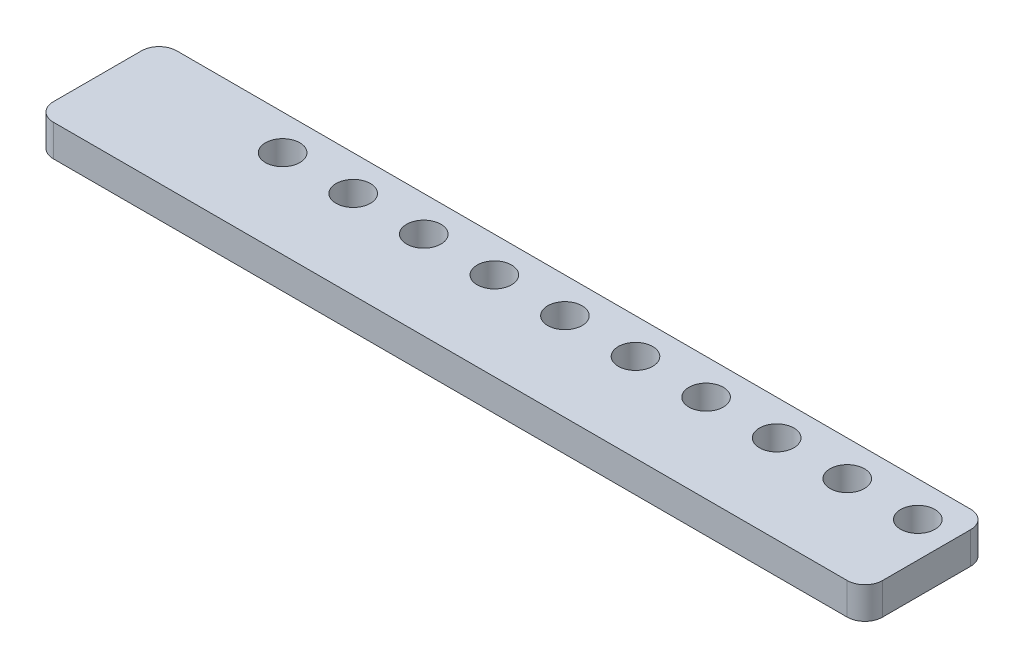
from build123d import *

# Parameters (mm, degrees)
BOSS_EXTRUDE1_DEPTH = 3.6
SKETCH2_R           = 1.95
CUT_EXTRUDE1_DEPTH  = 3.6


with BuildPart() as part:
    # Sketch1 → Boss-Extrude1 (new body)
    with BuildSketch(Plane(origin=(0, 0, 0), x_dir=(1, 0, 0), z_dir=(0, 1, 0))):
        with BuildLine():
            Line((2, 0), (92, 0))
            ThreePointArc((92, 0), (93.414213562, -0.585786438), (94, -2))
            Line((94, -2), (94, -12))
            ThreePointArc((94, -12), (93.414213562, -13.414213562), (92, -14))
            Line((92, -14), (2, -14))
            ThreePointArc((2, -14), (0.585786438, -13.414213562), (0, -12))
            Line((0, -12), (0, -2))
            ThreePointArc((0, -2), (0.585786438, -0.585786438), (2, 0))
        make_face()
    extrude(amount=BOSS_EXTRUDE1_DEPTH)

    # Sketch2 → Cut-Extrude1 (cut)
    with BuildSketch(Plane(origin=(0, 3.6, 0), x_dir=(1, 0, 0), z_dir=(0, 1, 0))):
        with Locations((90, -4)):
            Circle(SKETCH2_R)
        with Locations((82, -4)):
            Circle(SKETCH2_R)
        with Locations((18, -4)):
            Circle(SKETCH2_R)
        with Locations((26, -4)):
            Circle(SKETCH2_R)
        with Locations((34, -4)):
            Circle(SKETCH2_R)
        with Locations((42, -4)):
            Circle(SKETCH2_R)
        with Locations((50, -4)):
            Circle(SKETCH2_R)
        with Locations((58, -4)):
            Circle(SKETCH2_R)
        with Locations((66, -4)):
            Circle(SKETCH2_R)
        with Locations((74, -4)):
            Circle(SKETCH2_R)
    extrude(amount=-CUT_EXTRUDE1_DEPTH, mode=Mode.SUBTRACT)


solid = part.part
